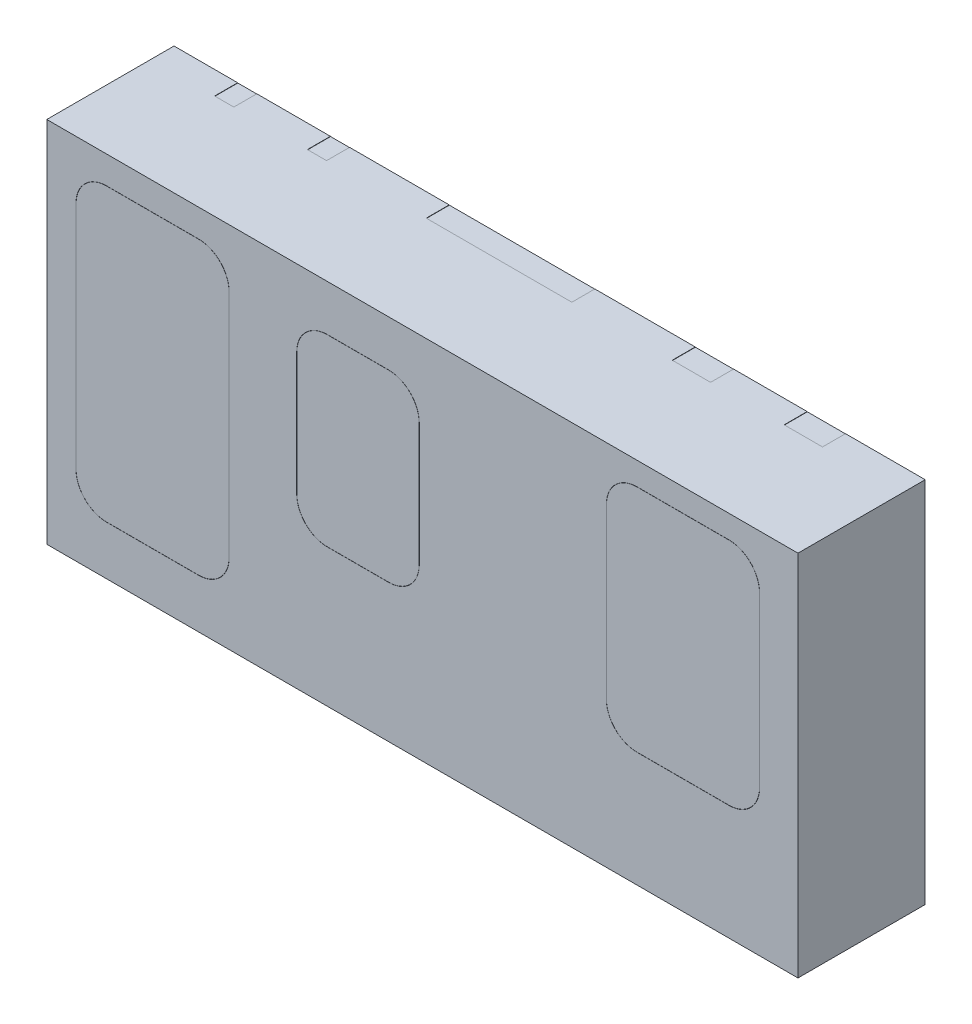
from build123d import *

# Parameters (mm, degrees)
SKETCH_1_W          = 4.9
SKETCH_1_H          = 2.4
EXTRUDE_320_DEPTH   = 0.83
CUT_EXTRUDE_1_DEPTH = 0.1
SKETCH_3_W          = 0.3
SKETCH_3_H          = 0.55
CUT_EXTRUDE_2_DEPTH = 0.15
EXTRUDE_1_DEPTH     = 0.15
SKETCH_5_W          = 0.298
SKETCH_5_H          = 0.548
EXTRUDE_2_DEPTH     = 0.15
EXTRUDE_3_DEPTH     = 0.1


with BuildPart() as part:
    # Эскиз1 → Extrude 320 (new body)
    with BuildSketch(Plane.XY):
        with Locations((2.45, 1.2)):
            Rectangle(SKETCH_1_W, SKETCH_1_H)
    extrude(amount=EXTRUDE_320_DEPTH)

    # Эскиз2 → Вырез-Вытянуть1 (cut)
    with BuildSketch(Plane.XY.offset(0.83)):
        with BuildLine():
            Line((3.85, 2.25), (4.45, 2.25))
            ThreePointArc((4.45, 2.25), (4.591421356, 2.191421356), (4.65, 2.05))
            Line((4.65, 2.05), (4.65, 0.95))
            ThreePointArc((4.65, 0.95), (4.591421356, 0.808578644), (4.45, 0.75))
            Line((4.45, 0.75), (3.85, 0.75))
            ThreePointArc((3.85, 0.75), (3.708578644, 0.808578644), (3.65, 0.95))
            Line((3.65, 0.95), (3.65, 2.05))
            ThreePointArc((3.65, 2.05), (3.708578644, 2.191421356), (3.85, 2.25))
        make_face()
        with BuildLine():
            Line((1.83, 2.1), (2.23, 2.1))
            ThreePointArc((2.23, 2.1), (2.371421356, 2.041421356), (2.43, 1.9))
            Line((2.43, 1.9), (2.43, 1.1))
            ThreePointArc((2.43, 1.1), (2.371421356, 0.958578644), (2.23, 0.9))
            Line((2.23, 0.9), (1.83, 0.9))
            ThreePointArc((1.83, 0.9), (1.688578644, 0.958578644), (1.63, 1.1))
            Line((1.63, 1.1), (1.63, 1.9))
            ThreePointArc((1.63, 1.9), (1.688578644, 2.041421356), (1.83, 2.1))
        make_face()
        with BuildLine():
            Line((0.39, 2.22), (0.99, 2.22))
            ThreePointArc((0.99, 2.22), (1.131421356, 2.161421356), (1.19, 2.02))
            Line((1.19, 2.02), (1.19, 0.52))
            ThreePointArc((1.19, 0.52), (1.131421356, 0.378578644), (0.99, 0.32))
            Line((0.99, 0.32), (0.39, 0.32))
            ThreePointArc((0.39, 0.32), (0.248578644, 0.378578644), (0.19, 0.52))
            Line((0.19, 0.52), (0.19, 2.02))
            ThreePointArc((0.19, 2.02), (0.248578644, 2.161421356), (0.39, 2.22))
        make_face()
    extrude(amount=-CUT_EXTRUDE_1_DEPTH, mode=Mode.SUBTRACT)

    # Эскиз3 → Вырез-Вытянуть2 (cut)
    with BuildSketch(Plane(origin=(0, 0, 0), x_dir=(-1, 0, 0), z_dir=(0, 0, -1))):
        with BuildLine():
            Line((-0.225, 1.2), (-1.335, 1.2))
            Line((-1.335, 1.2), (-1.335, 2.24))
            Line((-1.335, 2.24), (-1.145, 2.24))
            Line((-1.145, 2.24), (-1.145, 2.4))
            Line((-1.145, 2.4), (-1.02, 2.4))
            ThreePointArc((-1.02, 2.4), (-0.78, 2.16), (-0.54, 2.4))
            Line((-0.54, 2.4), (-0.415, 2.4))
            Line((-0.415, 2.4), (-0.415, 2.24))
            Line((-0.415, 2.24), (-0.225, 2.24))
            Line((-0.225, 2.24), (-0.225, 1.2))
        make_face()
        Polygon((-1.62, 0.9), (-2.92, 0.9), (-2.92, 2.24), (-2.745, 2.24), (-2.745, 2.4), (-1.795, 2.4), (-1.795, 2.24), (-1.62, 2.24), align=None)
        with BuildLine():
            Line((-3.24, 0.9), (-4.54, 0.9))
            Line((-4.54, 0.9), (-4.54, 2.24))
            Line((-4.54, 2.24), (-4.38, 2.24))
            Line((-4.38, 2.24), (-4.38, 2.4))
            Line((-4.38, 2.4), (-4.13, 2.4))
            ThreePointArc((-4.13, 2.4), (-3.89, 2.16), (-3.65, 2.4))
            Line((-3.65, 2.4), (-3.4, 2.4))
            Line((-3.4, 2.4), (-3.4, 2.24))
            Line((-3.4, 2.24), (-3.24, 2.24))
            Line((-3.24, 2.24), (-3.24, 0.9))
        make_face()
        Polygon((-0.5, 0), (-0.8, 0), (-0.8, 0.55), (-0.9, 0.55), (-0.9, 1), (-0.25, 1), (-0.25, 0.55), (-0.5, 0.55), align=None)
        Polygon((-1.485, 0), (-1.185, 0), (-1.185, 1), (-1.385, 1), (-1.385, 0.55), (-1.485, 0.55), align=None)
        with Locations((-2.02, 0.275)):
            Rectangle(SKETCH_3_W, SKETCH_3_H)
        with Locations((-2.705, 0.275)):
            Rectangle(SKETCH_3_W, SKETCH_3_H)
        with Locations((-3.39, 0.275)):
            Rectangle(SKETCH_3_W, SKETCH_3_H)
    extrude(amount=-CUT_EXTRUDE_2_DEPTH, mode=Mode.SUBTRACT)

    # Эскиз4 → Бобышка-Вытянуть1 (add)
    with BuildSketch(Plane(origin=(0, 0, 0.15), x_dir=(-1, 0, 0), z_dir=(0, 0, -1))):
        Polygon((-0.501, 0.001), (-0.501, 0.551), (-0.251, 0.551), (-0.251, 0.999), (-0.899, 0.999), (-0.899, 0.551), (-0.799, 0.551), (-0.799, 0.001), align=None)
    extrude(amount=EXTRUDE_1_DEPTH)

    # Эскиз5 → Бобышка-Вытянуть2 (add)
    with BuildSketch(Plane(origin=(0, 0, 0.15), x_dir=(-1, 0, 0), z_dir=(0, 0, -1))):
        Polygon((-1.484, 0.549), (-1.484, 0.001), (-1.186, 0.001), (-1.186, 0.999), (-1.384, 0.999), (-1.384, 0.549), align=None)
        with Locations((-2.02, 0.275)):
            Rectangle(SKETCH_5_W, SKETCH_5_H)
        with Locations((-2.705, 0.275)):
            Rectangle(SKETCH_5_W, SKETCH_5_H)
        with Locations((-3.39, 0.275)):
            Rectangle(SKETCH_5_W, SKETCH_5_H)
        with BuildLine():
            Line((-3.241, 0.901), (-3.241, 2.239))
            Line((-3.241, 2.239), (-3.401, 2.239))
            Line((-3.401, 2.239), (-3.401, 2.399))
            Line((-3.401, 2.399), (-3.649002075, 2.399))
            ThreePointArc((-3.649002075, 2.399), (-3.89, 2.159), (-4.130997925, 2.399))
            Line((-4.130997925, 2.399), (-4.379, 2.399))
            Line((-4.379, 2.399), (-4.379, 2.239))
            Line((-4.379, 2.239), (-4.539, 2.239))
            Line((-4.539, 2.239), (-4.539, 0.901))
            Line((-4.539, 0.901), (-3.241, 0.901))
        make_face()
        Polygon((-1.621, 0.901), (-1.621, 2.239), (-1.796, 2.239), (-1.796, 2.399), (-2.744, 2.399), (-2.744, 2.239), (-2.919, 2.239), (-2.919, 0.901), align=None)
        with BuildLine():
            Line((-0.226, 1.201), (-0.226, 2.239))
            Line((-0.226, 2.239), (-0.416, 2.239))
            Line((-0.416, 2.239), (-0.416, 2.399))
            Line((-0.416, 2.399), (-0.539002075, 2.399))
            ThreePointArc((-0.539002075, 2.399), (-0.78, 2.159), (-1.020997925, 2.399))
            Line((-1.020997925, 2.399), (-1.144, 2.399))
            Line((-1.144, 2.399), (-1.144, 2.239))
            Line((-1.144, 2.239), (-1.334, 2.239))
            Line((-1.334, 2.239), (-1.334, 1.201))
            Line((-1.334, 1.201), (-0.226, 1.201))
        make_face()
    extrude(amount=EXTRUDE_2_DEPTH)

    # Эскиз6 → Бобышка-Вытянуть3 (add)
    with BuildSketch(Plane.XY.offset(0.73)):
        with BuildLine():
            Line((3.85, 0.751), (4.45, 0.751))
            ThreePointArc((4.45, 0.751), (4.590714249, 0.809285751), (4.649, 0.95))
            Line((4.649, 0.95), (4.649, 2.05))
            ThreePointArc((4.649, 2.05), (4.590714249, 2.190714249), (4.45, 2.249))
            Line((4.45, 2.249), (3.85, 2.249))
            ThreePointArc((3.85, 2.249), (3.709285751, 2.190714249), (3.651, 2.05))
            Line((3.651, 2.05), (3.651, 0.95))
            ThreePointArc((3.651, 0.95), (3.709285751, 0.809285751), (3.85, 0.751))
        make_face()
        with BuildLine():
            Line((1.631, 1.9), (1.631, 1.1))
            ThreePointArc((1.631, 1.1), (1.689285751, 0.959285751), (1.83, 0.901))
            Line((1.83, 0.901), (2.23, 0.901))
            ThreePointArc((2.23, 0.901), (2.370714249, 0.959285751), (2.429, 1.1))
            Line((2.429, 1.1), (2.429, 1.9))
            ThreePointArc((2.429, 1.9), (2.370714249, 2.040714249), (2.23, 2.099))
            Line((2.23, 2.099), (1.83, 2.099))
            ThreePointArc((1.83, 2.099), (1.689285751, 2.040714249), (1.631, 1.9))
        make_face()
        with BuildLine():
            Line((0.39, 0.321), (0.99, 0.321))
            ThreePointArc((0.99, 0.321), (1.130714249, 0.379285751), (1.189, 0.52))
            Line((1.189, 0.52), (1.189, 2.02))
            ThreePointArc((1.189, 2.02), (1.130714249, 2.160714249), (0.99, 2.219))
            Line((0.99, 2.219), (0.39, 2.219))
            ThreePointArc((0.39, 2.219), (0.249285751, 2.160714249), (0.191, 2.02))
            Line((0.191, 2.02), (0.191, 0.52))
            ThreePointArc((0.191, 0.52), (0.249285751, 0.379285751), (0.39, 0.321))
        make_face()
    extrude(amount=EXTRUDE_3_DEPTH)


solid = part.part
